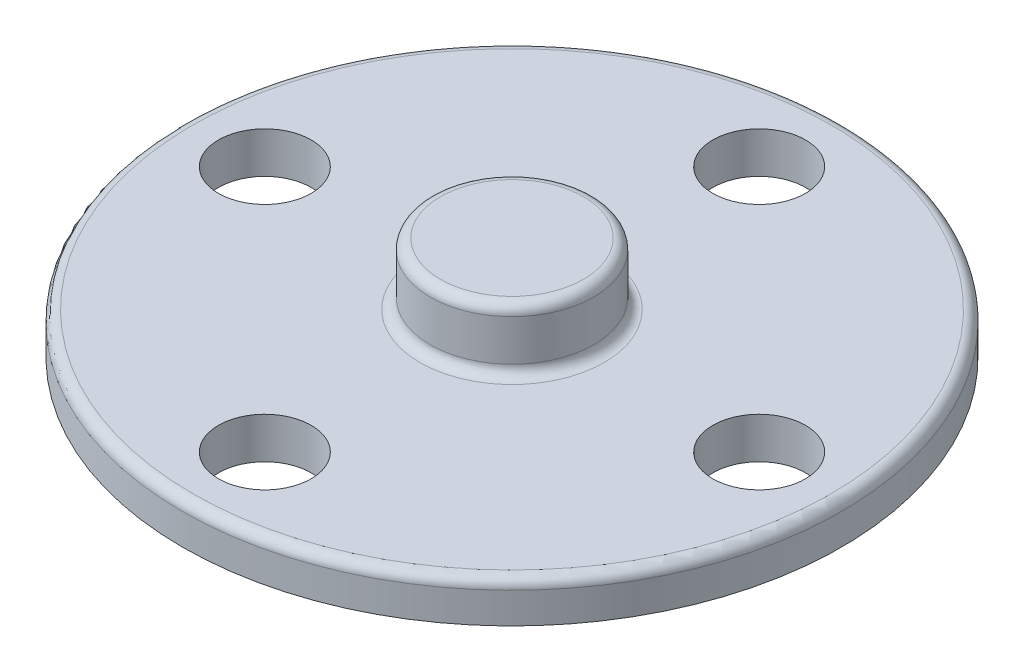
from build123d import *

# Parameters (mm, degrees)
SKETCH1_R           = 16
BOSS_EXTRUDE1_DEPTH = 2
SKETCH5_R           = 2.25
CUT_EXTRUDE1_DEPTH  = 3
SKETCH6_R           = 3.975
BOSS_EXTRUDE2_DEPTH = 3
FILLET1_R           = 0.5


with BuildPart() as part:
    # Sketch1 → Boss-Extrude1 (new body)
    with BuildSketch(Plane(origin=(0, 0, 0), x_dir=(1, 0, 0), z_dir=(0, 1, 0))):
        Circle(SKETCH1_R)
    extrude(amount=BOSS_EXTRUDE1_DEPTH)

    # Sketch5 → Cut-Extrude1 (cut, through all)
    with BuildSketch(Plane(origin=(0, 2, 0), x_dir=(1, 0, 0), z_dir=(0, 1, 0))):
        with Locations((0, 12)):
            Circle(SKETCH5_R)
        with Locations((12, 0)):
            Circle(SKETCH5_R)
        with Locations((0, -12)):
            Circle(SKETCH5_R)
        with Locations((-12, 0)):
            Circle(SKETCH5_R)
    extrude(amount=-CUT_EXTRUDE1_DEPTH, mode=Mode.SUBTRACT)

    # Sketch6 → Boss-Extrude2 (add)
    with BuildSketch(Plane(origin=(0, 2, 0), x_dir=(1, 0, 0), z_dir=(0, 1, 0))):
        Circle(SKETCH6_R)
    extrude(amount=BOSS_EXTRUDE2_DEPTH)

    # Fillet1
    fillet1_edges = [part.edges().sort_by_distance(p)[0] for p in [
        (-3.975, 2, 0),
        (-3.975, 5, 0),
        (-16, 2, 0),
    ]]
    fillet(fillet1_edges, radius=FILLET1_R)


solid = part.part
